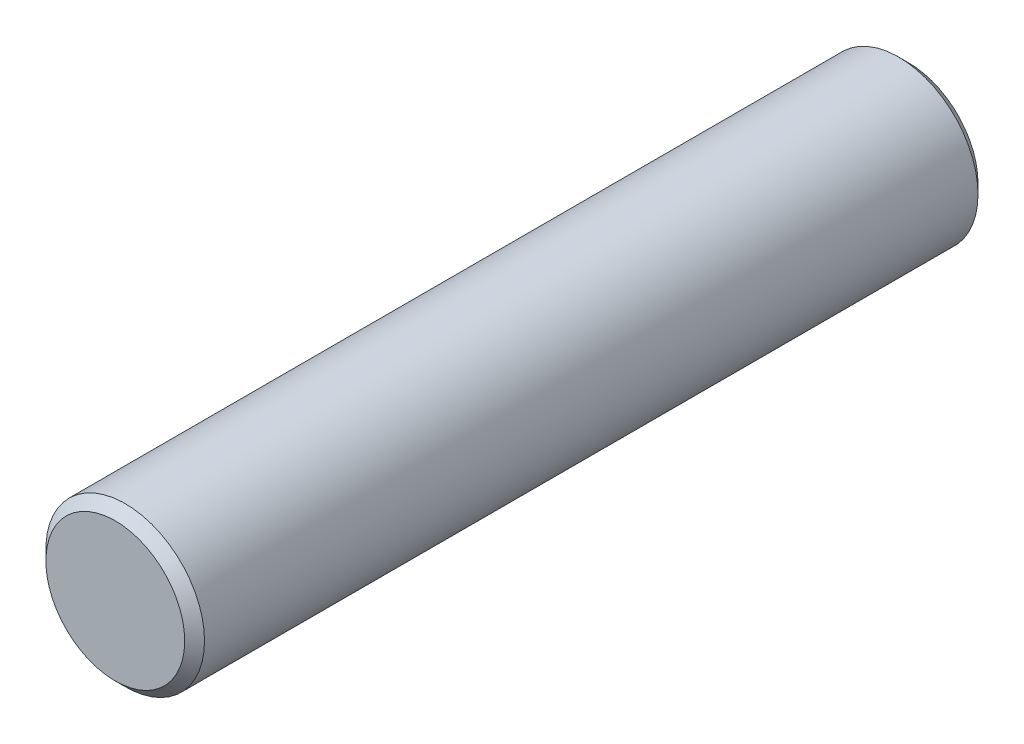
from build123d import *

# Parameters (mm, degrees)
SKETCH_1_R      = 4
EXTRUDE_1_DEPTH = 40
CHAMFER_1_SIZE  = 0.5


with BuildPart() as part:
    # 草图1 → 凸台-拉伸1 (new body)
    with BuildSketch(Plane.XY):
        Circle(SKETCH_1_R)
    extrude(amount=EXTRUDE_1_DEPTH)

    # 倒角1
    chamfer_1_edges = [part.edges().sort_by_distance(p)[0] for p in [
        (-4, 0, 0),
        (-4, 0, 40),
    ]]
    chamfer(chamfer_1_edges, length=CHAMFER_1_SIZE)


solid = part.part
